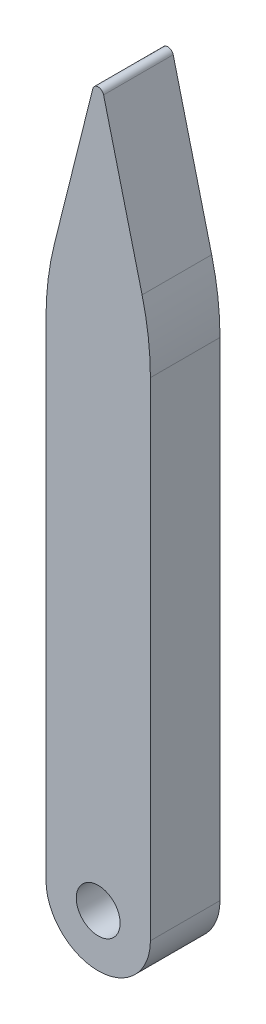
from build123d import *

# Parameters (mm, degrees)
SKETCH1_R           = 0.5
BOSS_EXTRUDE1_DEPTH = 1.5875
FILLET1_R           = 6.35
FILLET2_R           = 0.127


with BuildPart() as part:
    # Sketch1 → Boss-Extrude1 (new body)
    with BuildSketch(Plane.XY):
        with BuildLine():
            Line((-1.190625, -6), (-1.190625, 5.90625))
            Line((-1.190625, 5.90625), (0, 10.66875))
            Line((0, 10.66875), (1.190625, 5.90625))
            Line((1.190625, 5.90625), (1.190625, -6))
            ThreePointArc((1.190625, -6), (0, -7.190625), (-1.190625, -6))
        make_face()
        with Locations((0, -6)):
            Circle(SKETCH1_R, mode=Mode.SUBTRACT)
    extrude(amount=-BOSS_EXTRUDE1_DEPTH)

    # Fillet1
    fillet1_edges = [part.edges().sort_by_distance(p)[0] for p in [
        (-1.190625, 5.90625, -0.79375),
        (1.190625, 5.90625, -0.79375),
    ]]
    fillet(fillet1_edges, radius=FILLET1_R)

    # Fillet2
    fillet2_edges = [part.edges().sort_by_distance(p)[0] for p in [
        (0, 10.66875, -0.79375),
    ]]
    fillet(fillet2_edges, radius=FILLET2_R)


solid = part.part
